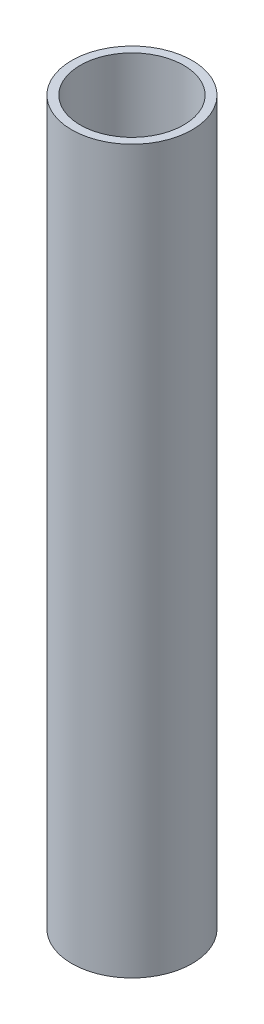
from build123d import *

# Parameters (mm, degrees)
SKETCH_1_R      = 25
SKETCH_1_R_2    = 21.5
EXTRUDE_1_DEPTH = 300


with BuildPart() as part:
    # Эскиз1 → Вытянуть-Тонкостенный1 (new body)
    with BuildSketch(Plane(origin=(0, 0, 0), x_dir=(1, 0, 0), z_dir=(0, 1, 0))):
        Circle(SKETCH_1_R)
        Circle(SKETCH_1_R_2, mode=Mode.SUBTRACT)
    extrude(amount=EXTRUDE_1_DEPTH)


solid = part.part
